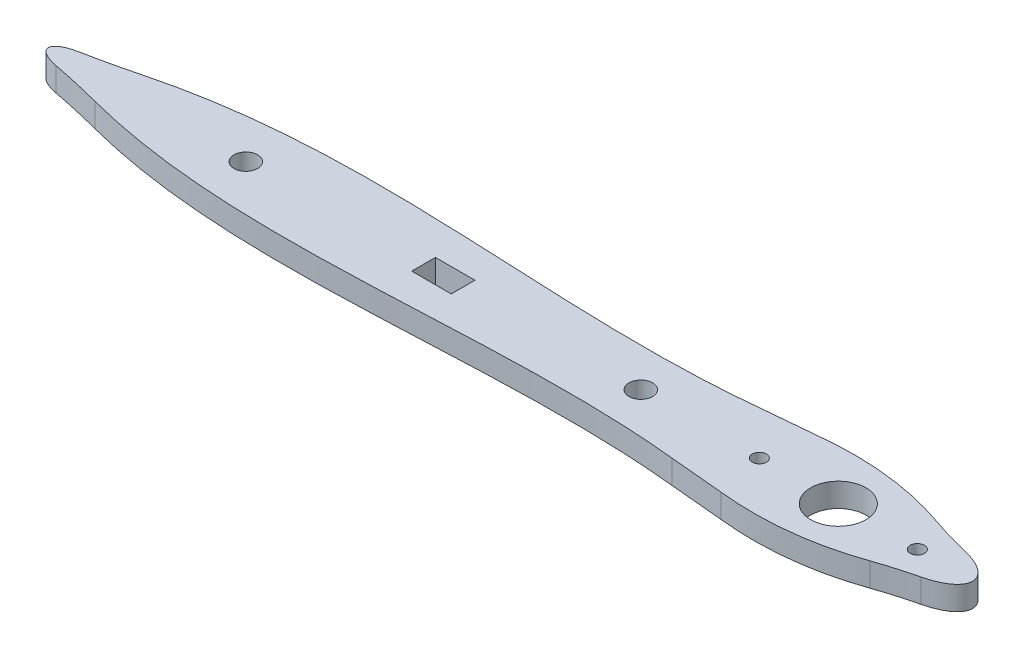
from build123d import *

# Parameters (mm, degrees)
ESBO_O1_R                = 3.5
ESBO_O1_R_2              = 0.9
ESBO_O1_R_3              = 1.5
ESBO_O1_W                = 5
ESBO_O1_H                = 3
RESSALTO_EXTRUS_O1_DEPTH = 3


with BuildPart() as part:
    # Esboço1 → Ressalto-extrusão1 (new body)
    with BuildSketch(Plane(origin=(0, 0, 0), x_dir=(1, 0, 0), z_dir=(0, 1, 0))):
        with BuildLine():
            Line((-15.5324261, 5.526900759), (-8.701477822, 6.15))
            add(Edge.make_bspline(
                [(8.269723742, 4.259468977), (2.834912713, 6.157347241), (-2.82215339, 6.787527354), (-8.701477822, 6.15)],
                knots=[0.35388944, 0.35388944, 0.35388944, 0.35388944, 1, 1, 1, 1], degree=3))
            ThreePointArc((8.269723742, 4.259468977), (10.737611567, 3.46879666), (13.24315076, 2.807051708))
            add(Edge.make_bspline(
                [(13.243153259, -2.80704963), (25.10877849, 2.12e-06), (13.24315076, 2.807051708)],
                knots=[5.194112275, 5.194112275, 5.194112275, 7.372258742, 7.372258742, 7.372258742], degree=2, weights=[1, 0.463306864, 1]))
            ThreePointArc((13.243153259, -2.80704963), (10.737612779, -3.468795552), (8.269723742, -4.259468977))
            add(Edge.make_bspline(
                [(8.269723742, -4.259468977), (2.834913243, -6.15734876), (-2.822153925, -6.787525817), (-8.701477822, -6.15)],
                knots=[0.35388944, 0.35388944, 0.35388944, 0.35388944, 1, 1, 1, 1], degree=3))
            Line((-8.701477822, -6.15), (-15.5324261, -5.526900759))
            add(Edge.make_bspline(
                [(-91.135478662, -2.939356415), (-85.814709071, -4.330378827), (-60.917561227, -7.97508816), (-35.132432713, -3.48955228), (-15.5324261, -5.526900759)],
                knots=[0.107974898, 0.107974898, 0.107974898, 0.107974898, 0.300967181, 1, 1, 1, 1], degree=3))
            ThreePointArc((-91.135478662, -2.939356415), (-94.330524557, -2.159963767), (-97.549471293, -1.486054958))
            add(Edge.make_bspline(
                [(-97.549471293, 1.486054958), (-105.279311729, 0), (-97.549471293, -1.486054958)],
                knots=[5.195092838, 5.195092838, 5.195092838, 7.371277776, 7.371277776, 7.371277776], degree=2, weights=[1, 0.464175793, 1]))
            ThreePointArc((-97.549471293, 1.486054958), (-94.330524557, 2.159963767), (-91.135478662, 2.939356415))
            add(Edge.make_bspline(
                [(-91.135478662, 2.939356415), (-85.814709071, 4.330378827), (-60.917561227, 7.97508816), (-35.132432713, 3.48955228), (-15.5324261, 5.526900759)],
                knots=[0.107974898, 0.107974898, 0.107974898, 0.107974898, 0.300967181, 1, 1, 1, 1], degree=3))
        make_face()
        Circle(ESBO_O1_R, mode=Mode.SUBTRACT)
        with Locations((10, 0)):
            Circle(ESBO_O1_R_2, mode=Mode.SUBTRACT)
        with Locations((-10, 0)):
            Circle(ESBO_O1_R_2, mode=Mode.SUBTRACT)
        with Locations((-25, 0)):
            Circle(ESBO_O1_R_3, mode=Mode.SUBTRACT)
        with Locations((-75, 0)):
            Circle(ESBO_O1_R_3, mode=Mode.SUBTRACT)
        with Locations((-50, 0)):
            Rectangle(ESBO_O1_W, ESBO_O1_H, mode=Mode.SUBTRACT)
    extrude(amount=RESSALTO_EXTRUS_O1_DEPTH)


solid = part.part
